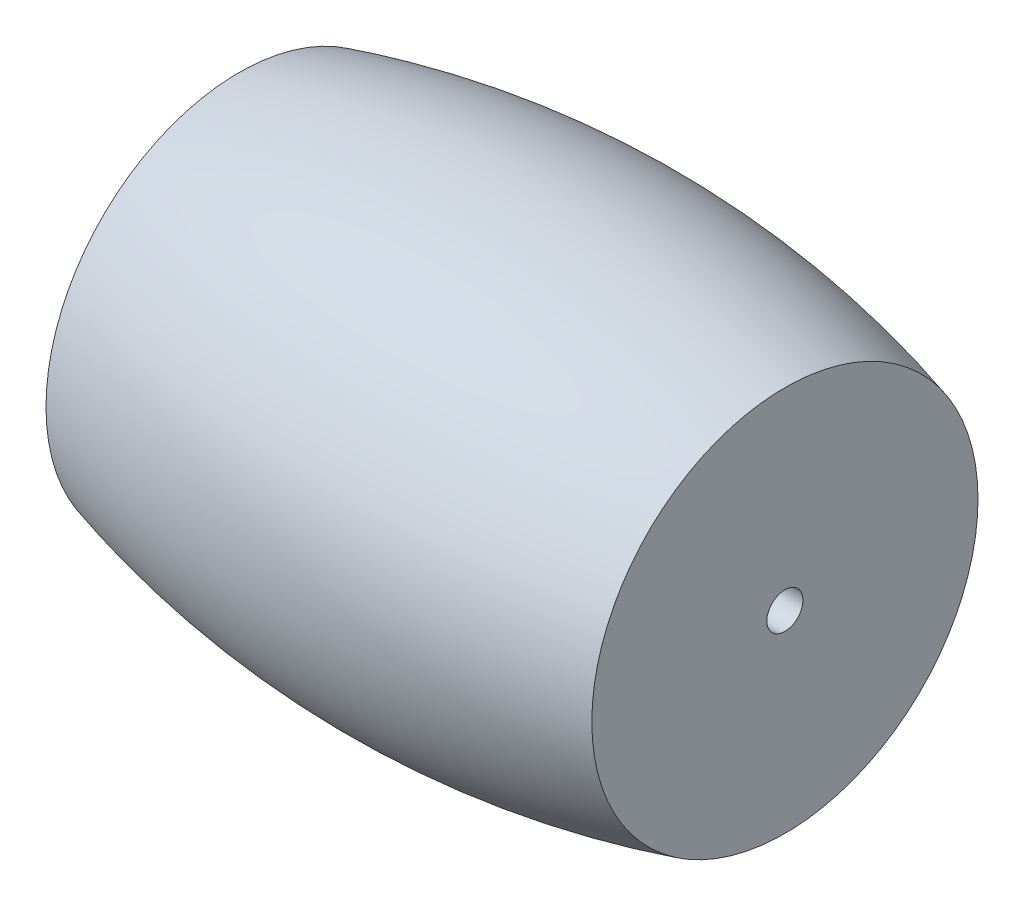
from build123d import *


with BuildPart() as part:
    # Sketch2 → Revolve2 (revolve)
    with BuildSketch(Plane.XY):
        with BuildLine():
            Line((-17.416428128, 1.15), (-17.416428128, 12.322080058))
            ThreePointArc((-17.416428128, 12.322080058), (0, 14.717989764), (17.416428128, 12.322080058))
            Line((17.416428128, 12.322080058), (17.416428128, 1.15))
            Line((17.416428128, 1.15), (-17.416428128, 1.15))
        make_face()
    revolve(axis=Axis((17.416428128, 0, 0), (-1, 0, 0)))


solid = part.part
